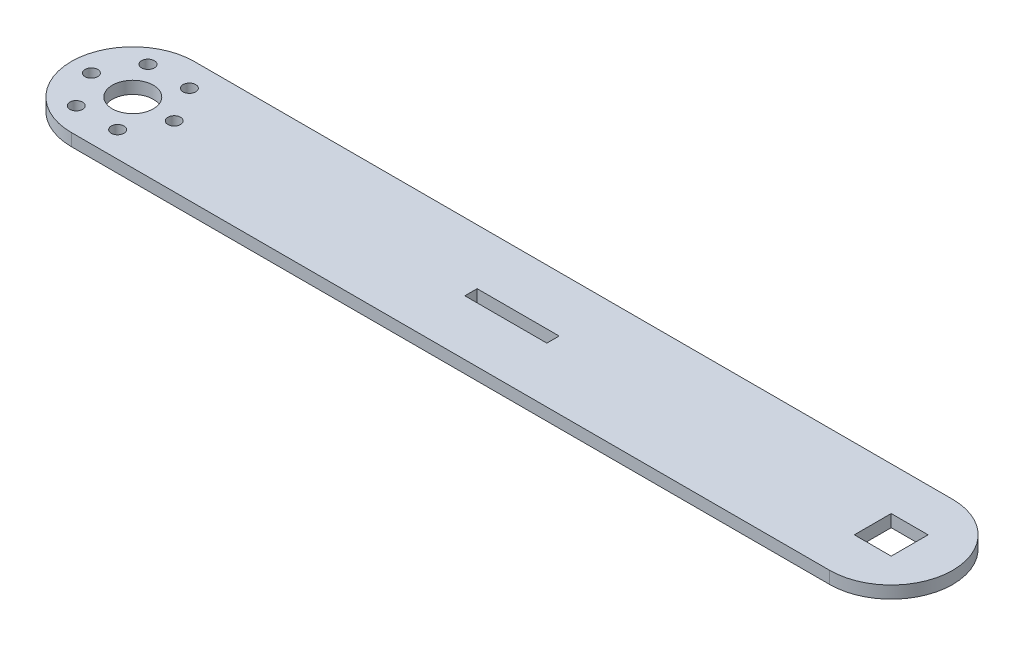
from build123d import *

# Parameters (mm, degrees)
SKETCH1_R           = 5
SKETCH1_R_2         = 1.55
SKETCH1_W           = 20
SKETCH1_H           = 3
SKETCH1_W_2         = 9
SKETCH1_H_2         = 9
BOSS_EXTRUDE1_DEPTH = 1.5


with BuildPart() as part:
    # Sketch1 → Boss-Extrude1 (new body, symmetric)
    with BuildSketch(Plane(origin=(0, 0, 0), x_dir=(1, 0, 0), z_dir=(0, 1, 0))):
        with BuildLine():
            Line((0, 15), (185, 15))
            ThreePointArc((185, 15), (200, 0), (185, -15))
            Line((185, -15), (0, -15))
            ThreePointArc((0, -15), (-15, 0), (0, 15))
        make_face()
        Circle(SKETCH1_R, mode=Mode.SUBTRACT)
        with Locations((5.051814855, 8.75)):
            Circle(SKETCH1_R_2, mode=Mode.SUBTRACT)
        with Locations((10.103629711, 0)):
            Circle(SKETCH1_R_2, mode=Mode.SUBTRACT)
        with Locations((5.051814855, -8.75)):
            Circle(SKETCH1_R_2, mode=Mode.SUBTRACT)
        with Locations((-5.051814855, -8.75)):
            Circle(SKETCH1_R_2, mode=Mode.SUBTRACT)
        with Locations((-10.103629711, 0)):
            Circle(SKETCH1_R_2, mode=Mode.SUBTRACT)
        with Locations((-5.051814855, 8.75)):
            Circle(SKETCH1_R_2, mode=Mode.SUBTRACT)
        with Locations((92.5, 0)):
            Rectangle(SKETCH1_W, SKETCH1_H, mode=Mode.SUBTRACT)
        with Locations((185, 0)):
            Rectangle(SKETCH1_W_2, SKETCH1_H_2, mode=Mode.SUBTRACT)
    extrude(amount=BOSS_EXTRUDE1_DEPTH, both=True)


solid = part.part
